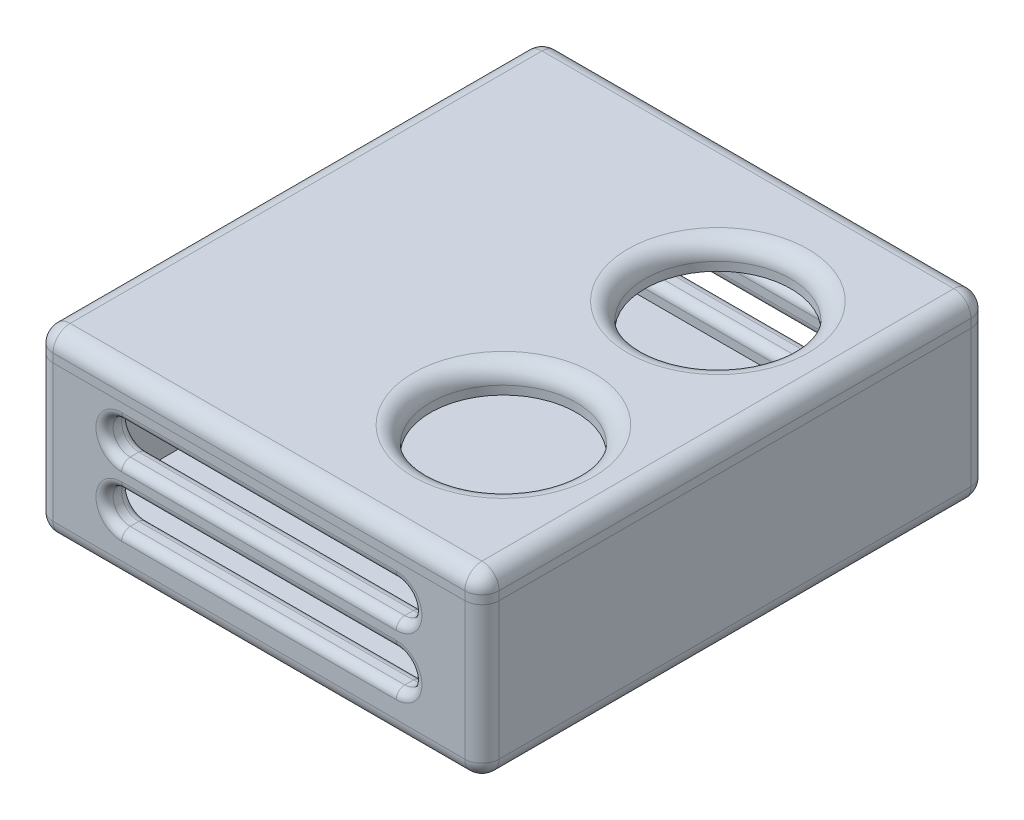
from build123d import *

# Parameters (mm, degrees)
SKETCH1_W           = 46
SKETCH1_H           = 53
BOSS_EXTRUDE1_DEPTH = 3
BOSS_EXTRUDE2_DEPTH = 18
BOSS_EXTRUDE3_START = 18
SKETCH1_6_W         = 23
SKETCH1_6_H         = 53
SKETCH1_6_R         = 8.5
BOSS_EXTRUDE3_DEPTH = 3
SKETCH4_R           = 2
CUT_EXTRUDE1_DEPTH  = 73.994862833
FILLET1_R           = 2
FILLET2_R           = 2
FILLET3_R           = 1


with BuildPart() as part:
    # Sketch1 → Boss-Extrude1 (new body)
    with BuildSketch(Plane(origin=(0, 0, 0), x_dir=(1, 0, 0), z_dir=(0, 1, 0))):
        with Locations((11.5, 0)):
            Rectangle(SKETCH1_W, SKETCH1_H)
    extrude(amount=BOSS_EXTRUDE1_DEPTH)

    # Sketch1_3 → Boss-Extrude2 (add)
    with BuildSketch(Plane(origin=(0, 0, 0), x_dir=(1, 0, 0), z_dir=(0, 1, 0))):
        Polygon((37.5, 29.5), (-11.5, 29.5), (-14.5, 29.5), (-14.5, -29.5), (37.5, -29.5), align=None)
        Polygon((11.5, -26.5), (-11.5, -26.5), (-11.5, 26.5), (11.5, 26.5), (34.5, 26.5), (34.5, -26.5), align=None, mode=Mode.SUBTRACT)
    extrude(amount=BOSS_EXTRUDE2_DEPTH)

    # Sketch4 → Cut-Extrude1 (cut, through all)
    with BuildSketch(Plane.XY.offset(29.5)):
        with Locations((-4.5, 14)):
            Circle(SKETCH4_R)
        with BuildLine():
            Line((27.5, 16), (-4.5, 16))
            ThreePointArc((-4.5, 16), (-3.085786438, 15.414213562), (-2.5, 14))
            ThreePointArc((-2.5, 14), (-3.085786438, 12.585786438), (-4.5, 12))
            Line((-4.5, 12), (27.5, 12))
            ThreePointArc((27.5, 12), (25.5, 14), (27.5, 16))
        make_face()
        with Locations((27.5, 14)):
            Circle(SKETCH4_R)
        with Locations((-4.5, 7)):
            Circle(SKETCH4_R)
        with BuildLine():
            Line((27.5, 9), (-4.5, 9))
            ThreePointArc((-4.5, 9), (-3.085786438, 8.414213562), (-2.5, 7))
            ThreePointArc((-2.5, 7), (-3.085786438, 5.585786438), (-4.5, 5))
            Line((-4.5, 5), (27.5, 5))
            ThreePointArc((27.5, 5), (25.5, 7), (27.5, 9))
        make_face()
        with Locations((27.5, 7)):
            Circle(SKETCH4_R)
    extrude(amount=-CUT_EXTRUDE1_DEPTH, mode=Mode.SUBTRACT)

    # Fillet1
    fillet1_edges = [part.edges().sort_by_distance(p)[0] for p in [
        (37.5, 0, 0),
        (37.5, 9, 29.5),
        (11.5, 0, -29.5),
        (37.5, 9, -29.5),
        (-14.5, 0, 0),
        (-14.5, 9, -29.5),
        (11.5, 0, 29.5),
        (-14.5, 9, 29.5),
    ]]
    fillet(fillet1_edges, radius=FILLET1_R)

    # Fillet3
    fillet3_edges = [part.edges().sort_by_distance(p)[0] for p in [
        (-6.5, 7, -26.5),
        (-6.5, 7, -29.5),
        (-6.5, 7, 26.5),
        (11.5, 9, -26.5),
        (29.5, 7, -26.5),
        (29.5, 7, -29.5),
        (29.5, 7, 26.5),
        (11.5, 5, -26.5),
        (11.5, 5, -29.5),
        (11.5, 5, 26.5),
        (11.5, 9, 26.5),
        (11.5, 9, 29.5),
        (11.5, 9, -29.5),
        (-6.5, 7, 29.5),
        (11.5, 5, 29.5),
        (29.5, 7, 29.5),
        (-6.5, 14, -26.5),
        (-6.5, 14, -29.5),
        (-6.5, 14, 26.5),
        (11.5, 16, -26.5),
        (29.5, 14, -26.5),
        (29.5, 14, -29.5),
        (29.5, 14, 26.5),
        (11.5, 12, -26.5),
        (11.5, 12, -29.5),
        (11.5, 12, 26.5),
        (11.5, 16, 26.5),
        (11.5, 16, 29.5),
        (11.5, 16, -29.5),
        (-6.5, 14, 29.5),
        (11.5, 12, 29.5),
        (29.5, 14, 29.5),
    ]]
    fillet(fillet3_edges, radius=FILLET3_R)


with BuildPart() as body_2:
    # Sketch1_6 → Boss-Extrude3 (new body)
    with BuildSketch(Plane(origin=(0, 0, 0), x_dir=(1, 0, 0), z_dir=(0, 1, 0)).offset(BOSS_EXTRUDE3_START)):
        Polygon((37.5, 29.5), (-11.5, 29.5), (-14.5, 29.5), (-14.5, -29.5), (37.5, -29.5), align=None)
        Polygon((11.5, -26.5), (-11.5, -26.5), (-11.5, 26.5), (11.5, 26.5), (34.5, 26.5), (34.5, -26.5), align=None, mode=Mode.SUBTRACT)
        with Locations((23, 0)):
            Rectangle(SKETCH1_6_W, SKETCH1_6_H)
        with Locations(Location((23, 12.5, 0), (0, 0, 270))):
            Circle(SKETCH1_6_R, mode=Mode.SUBTRACT)
        with Locations(Location((23, -12.5, 0), (0, 0, 270))):
            Circle(SKETCH1_6_R, mode=Mode.SUBTRACT)
        Rectangle(SKETCH1_6_W, SKETCH1_6_H)
    extrude(amount=BOSS_EXTRUDE3_DEPTH)

    # Fillet2
    fillet2_edges = [body_2.edges().sort_by_distance(p)[0] for p in [
        (11.5, 21, -29.5),
        (37.5, 19.5, 29.5),
        (-14.5, 19.5, 29.5),
        (-14.5, 19.5, -29.5),
        (37.5, 19.5, -29.5),
        (-14.5, 21, 0),
        (11.5, 21, 29.5),
        (23, 21, -21),
        (23, 21, 4),
        (37.5, 21, 0),
    ]]
    fillet(fillet2_edges, radius=FILLET2_R)


solid = Compound([part.part, body_2.part])
